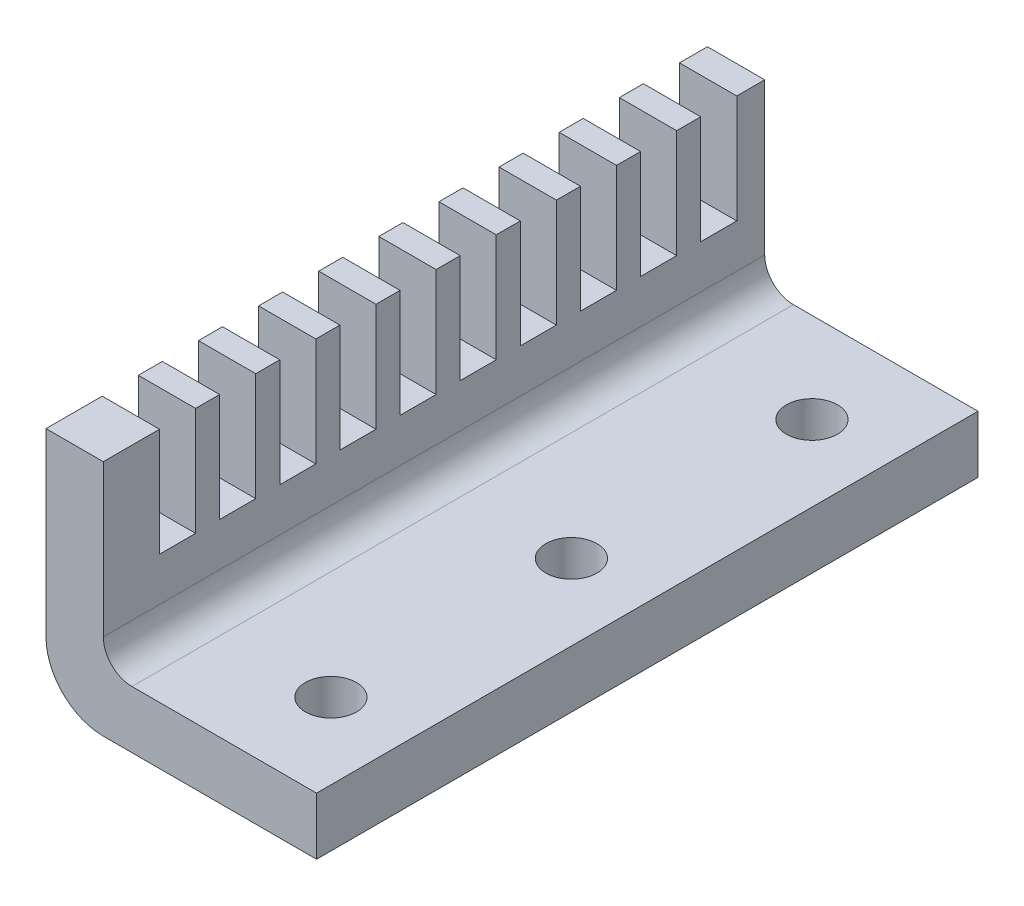
from build123d import *

# Parameters (mm, degrees)
RESSALTO_EXTRUS_O1_DEPTH                  = 110
ESBO_O2_W                                 = 6
ESBO_O2_H                                 = 18
CORTE_EXTRUS_O1_DEPTH                     = 10.53
BROCA_DE_ROSQUEAR_PARA_TARRAXA_DE_M10X1_D = 8.5


with BuildPart() as part:
    # Esboço1 → Ressalto-extrusão1 (new body)
    with BuildSketch(Plane.XY):
        with BuildLine():
            Line((9.53, 0), (45, 0))
            Line((45, 0), (45, 9.53))
            Line((45, 9.53), (14.295, 9.53))
            ThreePointArc((14.295, 9.53), (10.925636188, 10.925636188), (9.53, 14.295))
            Line((9.53, 14.295), (9.53, 39.53))
            Line((9.53, 39.53), (0, 39.53))
            Line((0, 39.53), (0, 9.53))
            ThreePointArc((0, 9.53), (2.791272375, 2.791272375), (9.53, 0))
        make_face()
    extrude(amount=RESSALTO_EXTRUS_O1_DEPTH)

    # Esboço2 → Corte-extrusão1 (cut, through all)
    with BuildSketch(Plane(origin=(9.53, 0, 0), x_dir=(0, 0, -1), z_dir=(1, 0, 0))):
        with Locations((-7.65, 30.53)):
            Rectangle(ESBO_O2_W, ESBO_O2_H)
        with Locations((-97.65, 30.53)):
            Rectangle(ESBO_O2_W, ESBO_O2_H)
        with Locations((-77.65, 30.53)):
            Rectangle(ESBO_O2_W, ESBO_O2_H)
        with Locations((-67.65, 30.53)):
            Rectangle(ESBO_O2_W, ESBO_O2_H)
        with Locations((-57.65, 30.53)):
            Rectangle(ESBO_O2_W, ESBO_O2_H)
        with Locations((-47.65, 30.53)):
            Rectangle(ESBO_O2_W, ESBO_O2_H)
        with Locations((-37.65, 30.53)):
            Rectangle(ESBO_O2_W, ESBO_O2_H)
        with Locations((-27.65, 30.53)):
            Rectangle(ESBO_O2_W, ESBO_O2_H)
        with Locations((-17.65, 30.53)):
            Rectangle(ESBO_O2_W, ESBO_O2_H)
        with Locations((-87.65, 30.53)):
            Rectangle(ESBO_O2_W, ESBO_O2_H)
    extrude(amount=-CORTE_EXTRUS_O1_DEPTH, mode=Mode.SUBTRACT)

    # Broca de rosquear para tarraxa de M10x1.51 (through all)
    with Locations(Plane(origin=(32.38, 9.53, 15), x_dir=(1, 0, 0), z_dir=(0, 1, 0))):
        with Locations((0, 0), (0, -40), (0, -80)):
            Hole(BROCA_DE_ROSQUEAR_PARA_TARRAXA_DE_M10X1_D / 2)


solid = part.part
